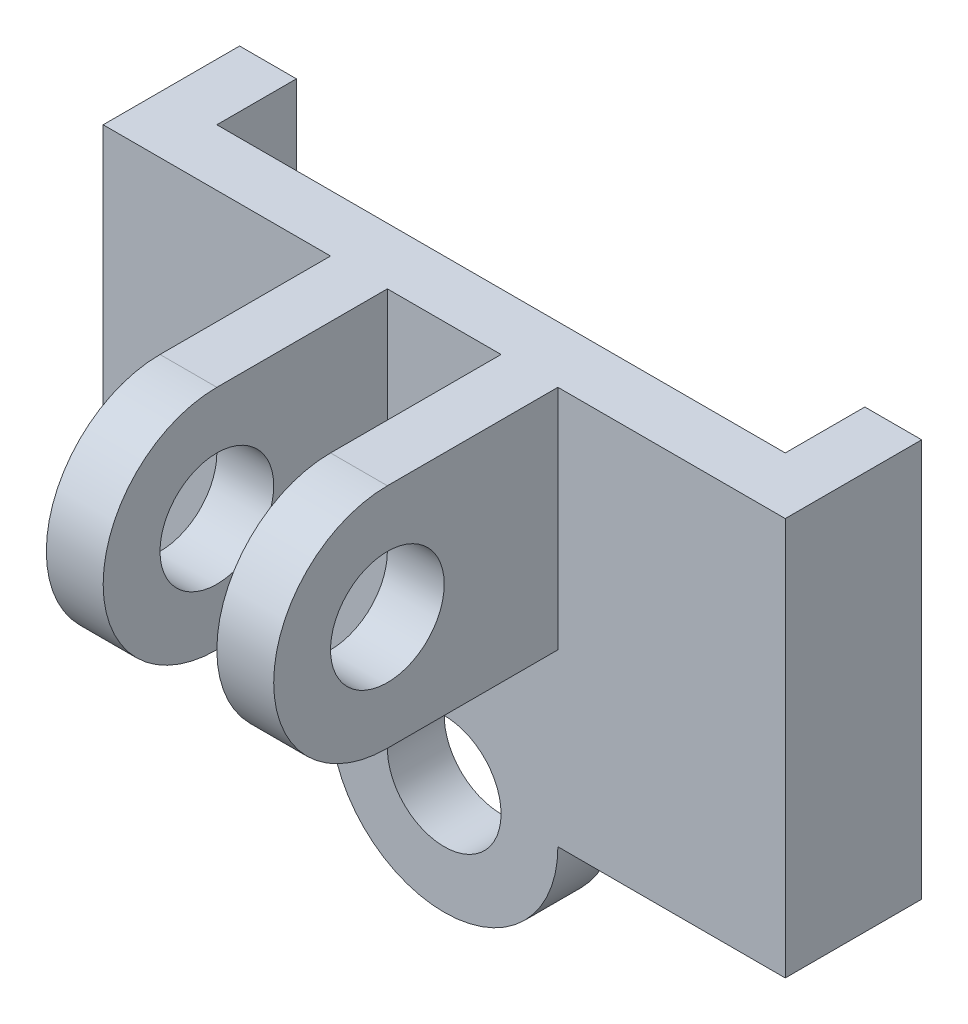
from build123d import *

# Parameters (mm, degrees)
BASE_EXTRUDE_DEPTH  = 12
SKETCH2_R           = 5
CUT_EXTRUDE1_DEPTH  = 12
SKETCH3_W           = 50
SKETCH3_H           = 7
CUT_EXTRUDE2_DEPTH  = 60
SKETCH4_W           = 5
SKETCH4_H           = 20
BOSS_EXTRUDE1_DEPTH = 15
BOSS_EXTRUDE2_DEPTH = 5
BOSS_EXTRUDE3_DEPTH = 5
SKETCH7_R           = 5
CUT_EXTRUDE3_DEPTH  = 40


with BuildPart() as part:
    # Sketch1 → Base-Extrude (new body)
    with BuildSketch(Plane.XY):
        with BuildLine():
            Line((0, 0), (20, 0))
            ThreePointArc((20, 0), (30, -10), (40, 0))
            Line((40, 0), (60, 0))
            Line((60, 0), (60, 35))
            Line((60, 35), (0, 35))
            Line((0, 35), (0, 0))
        make_face()
    extrude(amount=BASE_EXTRUDE_DEPTH)

    # Sketch2 → Cut-Extrude1 (cut)
    with BuildSketch(Plane.XY.offset(12)):
        with Locations((30, 0)):
            Circle(SKETCH2_R)
    extrude(amount=-CUT_EXTRUDE1_DEPTH, mode=Mode.SUBTRACT)

    # Sketch3 → Cut-Extrude2 (cut)
    with BuildSketch(Plane(origin=(0, 35, 0), x_dir=(-1, 0, 0), z_dir=(0, 1, 0))):
        with Locations((-30, 3.5)):
            Rectangle(SKETCH3_W, SKETCH3_H)
    extrude(amount=-CUT_EXTRUDE2_DEPTH, mode=Mode.SUBTRACT)

    # Sketch4 → Boss-Extrude1 (add)
    with BuildSketch(Plane.XY.offset(12)):
        with Locations((22.5, 25)):
            Rectangle(SKETCH4_W, SKETCH4_H)
        with Locations((37.5, 25)):
            Rectangle(SKETCH4_W, SKETCH4_H)
    extrude(amount=BOSS_EXTRUDE1_DEPTH)

    # Sketch5 → Boss-Extrude2 (add)
    with BuildSketch(Plane(origin=(40, 0, 0), x_dir=(0, 0, -1), z_dir=(1, 0, 0))):
        with BuildLine():
            Line((-27, 35), (-27, 21))
            Line((-27, 21), (-27, 15))
            ThreePointArc((-27, 15), (-37, 25), (-27, 35))
        make_face()
    extrude(amount=-BOSS_EXTRUDE2_DEPTH)

    # Sketch6 → Boss-Extrude3 (add)
    with BuildSketch(Plane.ZY.offset(-20)):
        with BuildLine():
            Line((27, 35), (27, 15))
            ThreePointArc((27, 15), (37, 25), (27, 35))
        make_face()
    extrude(amount=-BOSS_EXTRUDE3_DEPTH)

    # Sketch7 → Cut-Extrude3 (cut)
    with BuildSketch(Plane(origin=(40, 0, 0), x_dir=(0, 0, -1), z_dir=(1, 0, 0))):
        with Locations((-27, 25)):
            Circle(SKETCH7_R)
    extrude(amount=-CUT_EXTRUDE3_DEPTH, mode=Mode.SUBTRACT)


solid = part.part
